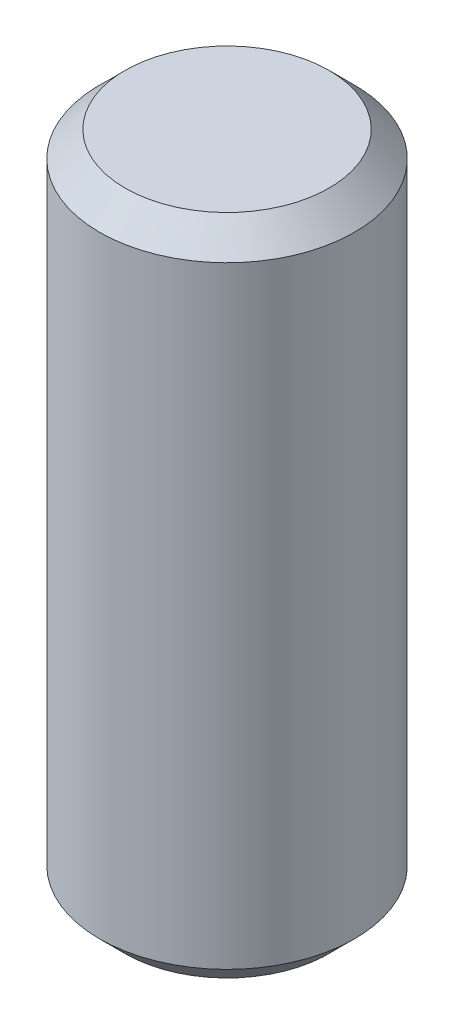
from build123d import *

# Parameters (mm, degrees)
SKETCH1_R           = 10
BOSS_EXTRUDE1_DEPTH = 52
CHAMFER1_SIZE       = 2


with BuildPart() as part:
    # Sketch1 → Boss-Extrude1 (new body)
    with BuildSketch(Plane(origin=(0, 0, 0), x_dir=(1, 0, 0), z_dir=(0, 1, 0))):
        Circle(SKETCH1_R)
    extrude(amount=BOSS_EXTRUDE1_DEPTH)

    # Chamfer1
    chamfer1_edges = [part.edges().sort_by_distance(p)[0] for p in [
        (-10, 0, 0),
        (-10, 52, 0),
    ]]
    chamfer(chamfer1_edges, length=CHAMFER1_SIZE)


solid = part.part
